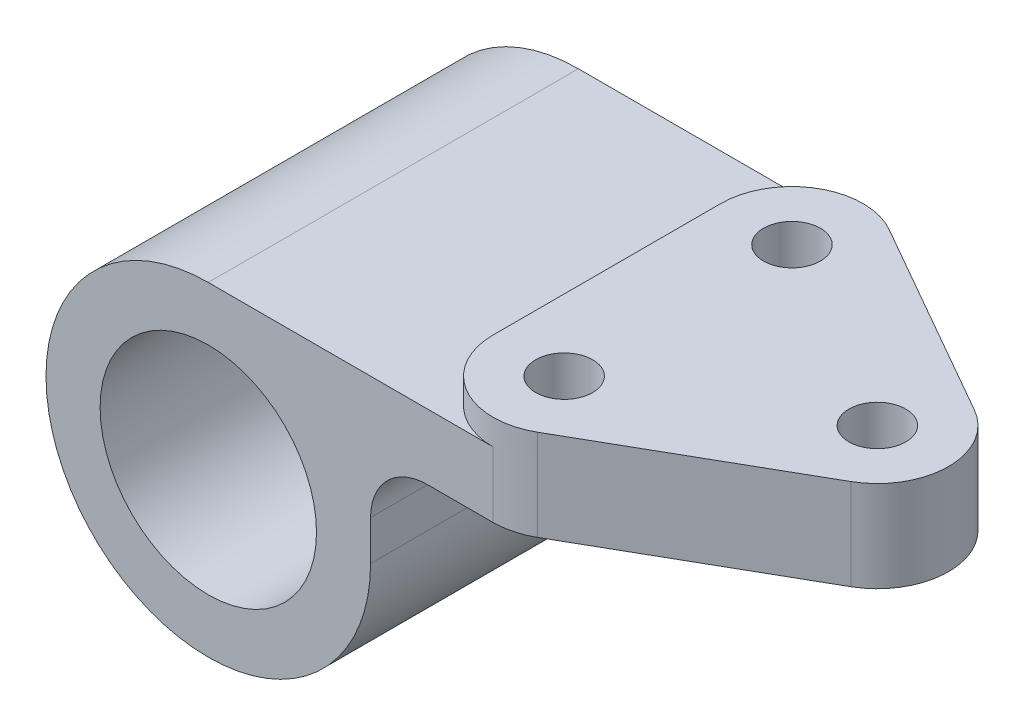
from build123d import *

# Parameters (mm, degrees)
SKETCH1_R           = 19
BOSS_EXTRUDE1_DEPTH = 32.5
CUT_EXTRUDE3_REACH  = 121.77
SKETCH2_R           = 5
CUT_EXTRUDE4_DEPTH  = 4.5


with BuildPart() as part:
    # Sketch1 → Boss-Extrude1 (new, symmetric)
    with BuildSketch(Plane.XY):
        with BuildLine():
            Line((37.5, 28.5), (0, 28.5))
            ThreePointArc((0, 28.5), (-20.152543264, -20.152543264), (28.5, 0))
            Line((28.5, 0), (28.5, 7))
            ThreePointArc((28.5, 7), (31.428932188, 14.071067812), (38.5, 17))
            Line((38.5, 17), (97.5, 17))
            Line((97.5, 17), (97.5, 33))
            Line((97.5, 33), (37.5, 33))
            Line((37.5, 33), (37.5, 28.5))
        make_face()
        Circle(SKETCH1_R, mode=Mode.SUBTRACT)
    extrude(amount=BOSS_EXTRUDE1_DEPTH, both=True)

    # Sketch2 → Cut-Extrude3 (cut, up to next)
    with BuildSketch(Plane(origin=(0, 33, 0), x_dir=(1, 0, 0), z_dir=(0, 1, 0)), mode=Mode.PRIVATE) as cut_extrude3_sk1:
        with BuildLine():
            ThreePointArc((56.201736729, -30.853039277), (53.208349189, -32.08124561), (50, -32.5))
            Line((50, -32.5), (97.5, -32.5))
            Line((97.5, -32.5), (97.5, 1.68e-07))
            ThreePointArc((97.5, 1.68e-07), (95.811376206, -6.274085155), (91.201736729, -10.853039277))
            Line((91.201736729, -10.853039277), (56.201736729, -30.853039277))
        make_face()
    cut_extrude3_tool1 = extrude(cut_extrude3_sk1.sketch, amount=-CUT_EXTRUDE3_REACH, mode=Mode.PRIVATE) & part.part
    # Sketch2 → Cut-Extrude3 (cut, up to next)
    with BuildSketch(Plane(origin=(0, 33, 0), x_dir=(1, 0, 0), z_dir=(0, 1, 0)), mode=Mode.PRIVATE) as cut_extrude3_sk2:
        with BuildLine():
            Line((97.5, 32.5), (50, 32.5))
            ThreePointArc((50, 32.5), (53.208349189, 32.08124561), (56.201736729, 30.853039277))
            Line((56.201736729, 30.853039277), (91.201736729, 10.853039277))
            ThreePointArc((91.201736729, 10.853039277), (95.811376122, 6.2740853), (97.5, 1.68e-07))
            Line((97.5, 1.68e-07), (97.5, 32.5))
        make_face()
    cut_extrude3_tool2 = extrude(cut_extrude3_sk2.sketch, amount=-CUT_EXTRUDE3_REACH, mode=Mode.PRIVATE) & part.part
    # Sketch2 → Cut-Extrude3 (cut, up to next)
    with BuildSketch(Plane(origin=(0, 33, 0), x_dir=(1, 0, 0), z_dir=(0, 1, 0)), mode=Mode.PRIVATE) as cut_extrude3_sk3:
        with Locations((50, 20)):
            Circle(SKETCH2_R)
    cut_extrude3_tool3 = extrude(cut_extrude3_sk3.sketch, amount=-CUT_EXTRUDE3_REACH, mode=Mode.PRIVATE) & part.part
    # Sketch2 → Cut-Extrude3 (cut, up to next)
    with BuildSketch(Plane(origin=(0, 33, 0), x_dir=(1, 0, 0), z_dir=(0, 1, 0)), mode=Mode.PRIVATE) as cut_extrude3_sk4:
        with Locations((50, -20)):
            Circle(SKETCH2_R)
    cut_extrude3_tool4 = extrude(cut_extrude3_sk4.sketch, amount=-CUT_EXTRUDE3_REACH, mode=Mode.PRIVATE) & part.part
    # Sketch2 → Cut-Extrude3 (cut, up to next)
    with BuildSketch(Plane(origin=(0, 33, 0), x_dir=(1, 0, 0), z_dir=(0, 1, 0)), mode=Mode.PRIVATE) as cut_extrude3_sk5:
        with Locations((85, 0)):
            Circle(SKETCH2_R)
    cut_extrude3_tool5 = extrude(cut_extrude3_sk5.sketch, amount=-CUT_EXTRUDE3_REACH, mode=Mode.PRIVATE) & part.part
    add(cut_extrude3_tool1.solids().sort_by_distance((82.925685, 33, 23.833798))[0], mode=Mode.SUBTRACT)
    add(cut_extrude3_tool2.solids().sort_by_distance((82.925685, 33, -23.833798))[0], mode=Mode.SUBTRACT)
    add(cut_extrude3_tool3.solids().sort_by_distance((50, 33, -20))[0], mode=Mode.SUBTRACT)
    add(cut_extrude3_tool4.solids().sort_by_distance((50, 33, 20))[0], mode=Mode.SUBTRACT)
    add(cut_extrude3_tool5.solids().sort_by_distance((85, 33, 0))[0], mode=Mode.SUBTRACT)

    # Sketch2_4 → Cut-Extrude4 (cut)
    with BuildSketch(Plane(origin=(0, 33, 0), x_dir=(1, 0, 0), z_dir=(0, 1, 0))):
        with BuildLine():
            ThreePointArc((50, -32.5), (41.161165235, -28.838834765), (37.5, -20))
            Line((37.5, -20), (37.5, -32.5))
            Line((37.5, -32.5), (50, -32.5))
        make_face()
        with BuildLine():
            Line((37.5, 32.5), (37.5, 20))
            ThreePointArc((37.5, 20), (41.161165235, 28.838834765), (50, 32.5))
            Line((50, 32.5), (37.5, 32.5))
        make_face()
    extrude(amount=-CUT_EXTRUDE4_DEPTH, mode=Mode.SUBTRACT)


solid = part.part
